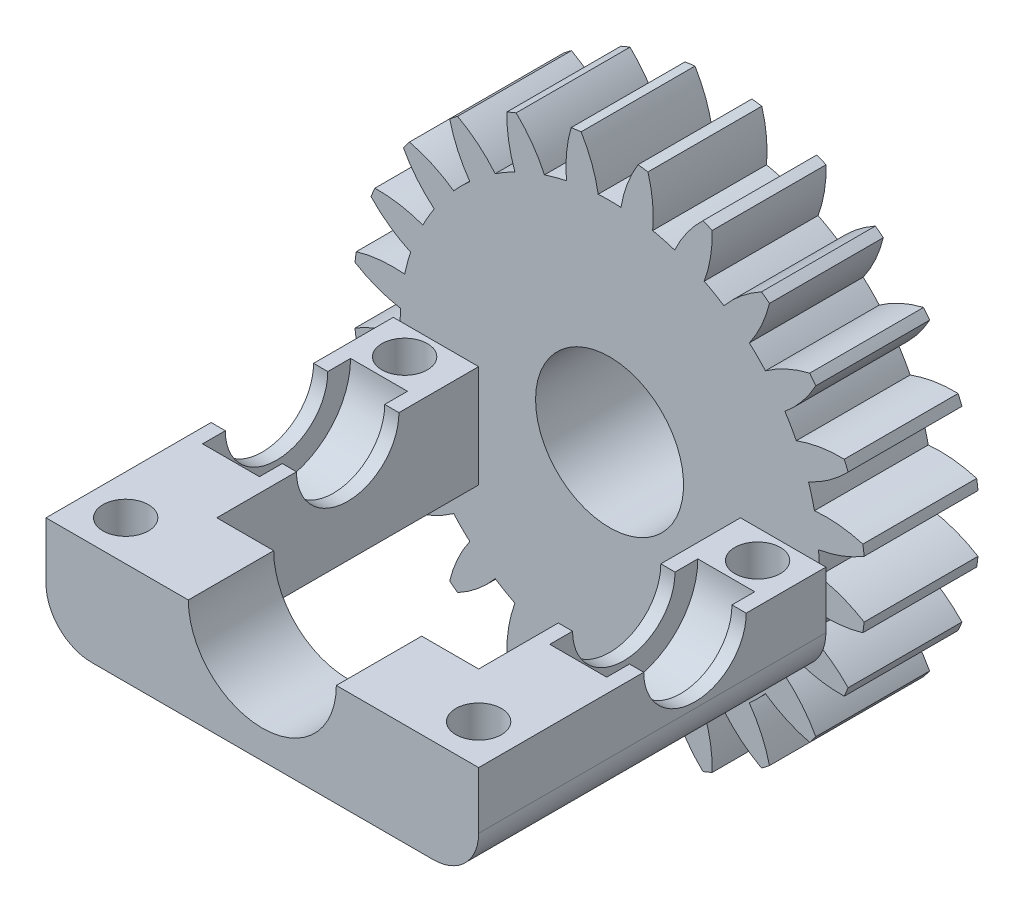
from build123d import *

# Parameters (mm, degrees)
BOSS_EXTRUDE1_DEPTH     = 9
SKETCH2_R               = 6.5
CUT_EXTRUDE1_DEPTH      = 2.5
SKETCH3_R               = 4.5
CUT_EXTRUDE2_DEPTH      = 20
SKETCH5_R               = 22.5
BOSS_EXTRUDE2_DEPTH     = 10
FILLET1_R               = 4
SKETCH4_R               = 6.5
CUT_EXTRUDE3_DEPTH      = 20
CUT_EXTRUDE3_DEPTH_BACK = 22.5
SKETCH6_R               = 2
CUT_EXTRUDE4_DEPTH      = 23.5
CUT_EXTRUDE5_DEPTH      = 10
CIRPATTERN1_COUNT       = 24


with BuildPart() as part:
    # Sketch1 → Boss-Extrude1 (new body)
    with BuildSketch(Plane(origin=(0, 0, 0), x_dir=(1, 0, 0), z_dir=(0, 1, 0))):
        Polygon((-19, 11.5), (-19, -19), (19, -19), (19, 11.5), (11.5, 11.5), (11.5, -11.5), (-11.5, -11.5), (-11.5, 11.5), align=None)
    extrude(amount=BOSS_EXTRUDE1_DEPTH)

    # Sketch2 → Cut-Extrude1 (cut, symmetric)
    with BuildSketch(Plane(origin=(15.25, 0, 0), x_dir=(0, 0, -1), z_dir=(1, 0, 0))):
        with Locations((0, 9)):
            Circle(SKETCH2_R)
    cut_extrude1 = extrude(amount=CUT_EXTRUDE1_DEPTH, both=True, mode=Mode.SUBTRACT)

    # Sketch3 → Cut-Extrude2 (cut, through all)
    with BuildSketch(Plane(origin=(0, 0, 0), x_dir=(0, 0, -1), z_dir=(1, 0, 0))):
        with Locations((0, 9)):
            Circle(SKETCH3_R)
    cut_extrude2 = extrude(amount=CUT_EXTRUDE2_DEPTH, mode=Mode.SUBTRACT)

    # Mirror1: Cut-Extrude1, Cut-Extrude2 across plane
    add(cut_extrude1.mirror(Plane(origin=(0, 0, 0), x_dir=(0, 0, 1), z_dir=(1, 0, 0))), mode=Mode.SUBTRACT)
    add(cut_extrude2.mirror(Plane(origin=(0, 0, 0), x_dir=(0, 0, 1), z_dir=(1, 0, 0))), mode=Mode.SUBTRACT)

    # Sketch5 → Boss-Extrude2 (add)
    with BuildSketch(Plane(origin=(0, 0, -11.5), x_dir=(-1, 0, 0), z_dir=(0, 0, -1))):
        with Locations((0, 9)):
            Circle(SKETCH5_R)
    extrude(amount=BOSS_EXTRUDE2_DEPTH)

    # Fillet1
    fillet1_edges = [part.edges().sort_by_distance(p)[0] for p in [
        (19, 0, 3.75),
        (-19, 0, 3.75),
    ]]
    fillet(fillet1_edges, radius=FILLET1_R)

    # Sketch4 → Cut-Extrude3 (cut, two sides)
    with BuildSketch(Plane.XY) as cut_extrude3_sk:
        with Locations((0, 9)):
            Circle(SKETCH4_R)
    extrude(amount=CUT_EXTRUDE3_DEPTH, mode=Mode.SUBTRACT)
    extrude(cut_extrude3_sk.sketch, amount=-CUT_EXTRUDE3_DEPTH_BACK, mode=Mode.SUBTRACT)

    # Sketch6 → Cut-Extrude4 (cut, through all)
    with BuildSketch(Plane(origin=(0, 9, 0), x_dir=(1, 0, 0), z_dir=(0, 1, 0))):
        with Locations((-15.5, -15.5)):
            Circle(SKETCH6_R)
        with Locations((15.5, -15.5)):
            Circle(SKETCH6_R)
        with Locations((15.5, 9)):
            Circle(SKETCH6_R)
        with Locations((-15.5, 9)):
            Circle(SKETCH6_R)
    extrude(amount=-CUT_EXTRUDE4_DEPTH, mode=Mode.SUBTRACT)

    # Sketch7 → Cut-Extrude5 (cut)
    with BuildSketch(Plane(origin=(0, 0, -21.5), x_dir=(-1, 0, 0), z_dir=(0, 0, -1))):
        with BuildLine():
            ThreePointArc((-2.5, 31.360679775), (-1.560980216, 29.431562194), (-1, 27.360679775))
            ThreePointArc((-1, 27.360679775), (0, 27.387891717), (1, 27.360679775))
            ThreePointArc((1, 27.360679775), (1.560980216, 29.431562194), (2.5, 31.360679775))
            ThreePointArc((2.5, 31.360679775), (0, 31.5), (-2.5, 31.360679775))
        make_face()
    cut_extrude5 = extrude(amount=-CUT_EXTRUDE5_DEPTH, mode=Mode.SUBTRACT)

    # CirPattern1: Cut-Extrude5 ×24 about axis
    cirpattern1_axis = Axis((0, 9, 0), (0, 0, 1))
    for i in range(1, CIRPATTERN1_COUNT):
        add(cut_extrude5.rotate(cirpattern1_axis, i * 360 / CIRPATTERN1_COUNT), mode=Mode.SUBTRACT)


solid = part.part
